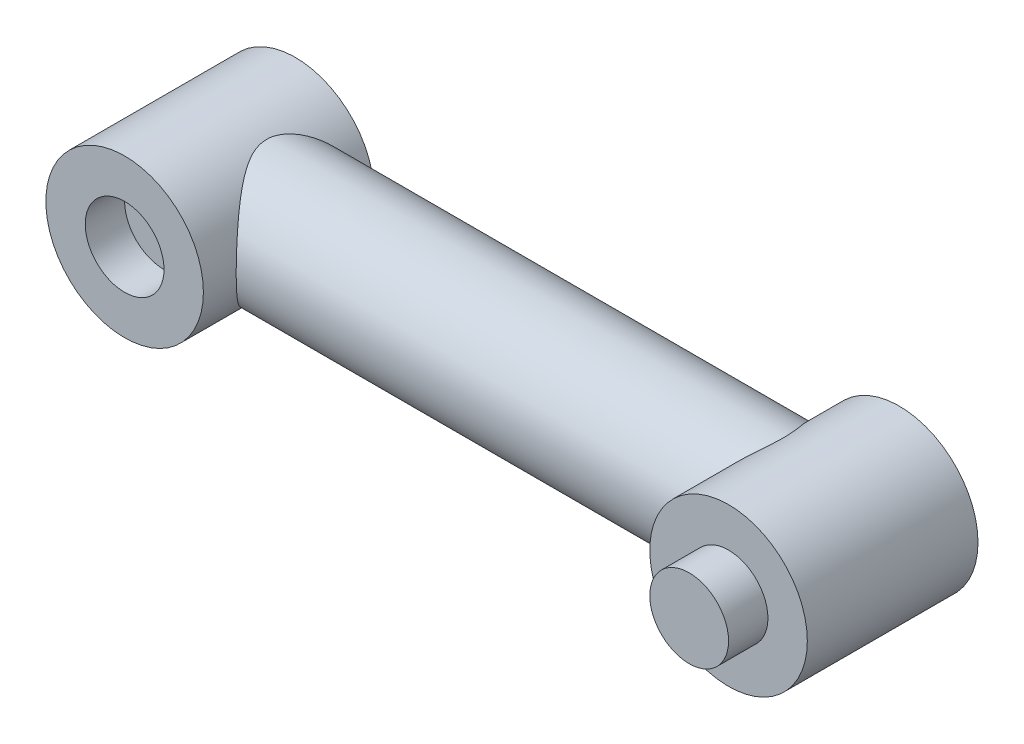
from build123d import *

# Parameters (mm, degrees)
BOSS_EXTRUDE1_START   = 5
SKETCH1_R             = 30
BOSS_EXTRUDE1_DEPTH   = 32.5
BOSS_EXTRUDE1_2_DEPTH = 32.5
SKETCH1_3_ONE_SIDE_W  = 196.833752096
SKETCH1_3_ONE_SIDE_H  = 25
CUT_EXTRUDE1_START    = 37.5
SKETCH1_4_R           = 15
CUT_EXTRUDE1_DEPTH    = 15
BOSS_EXTRUDE2_START   = 37.5
SKETCH1_5_R           = 15
BOSS_EXTRUDE2_DEPTH   = 15


with BuildPart() as part:
    # Sketch1 → Boss-Extrude1 (new body, symmetric)
    with BuildSketch(Plane.XY.offset(BOSS_EXTRUDE1_START)):
        Circle(SKETCH1_R)
    extrude(amount=BOSS_EXTRUDE1_DEPTH, both=True)



with BuildPart() as body_2:
    # Sketch1 → Boss-Extrude1 2 (new body, symmetric)
    with BuildSketch(Plane.XY.offset(BOSS_EXTRUDE1_START)):
        with Locations((230, 0)):
            Circle(SKETCH1_R)
    extrude(amount=BOSS_EXTRUDE1_2_DEPTH, both=True)


with BuildPart() as part_1:
    add(part.part)

    add(body_2.part)  # Revolve1 merges body 2
    # Sketch1_3 one side → Revolve1 (revolve)
    with BuildSketch(Plane.XY):
        with Locations((115, 12.5)):
            Rectangle(SKETCH1_3_ONE_SIDE_W, SKETCH1_3_ONE_SIDE_H)
    revolve(axis=Axis((213.416876048, 0, 0), (-1, 0, 0)))

    # Sketch1_4 → Cut-Extrude1 (cut)
    with BuildSketch(Plane.XY.offset(CUT_EXTRUDE1_START)):
        Circle(SKETCH1_4_R)
    extrude(amount=-CUT_EXTRUDE1_DEPTH, mode=Mode.SUBTRACT)

    # Sketch1_5 → Boss-Extrude2 (add)
    with BuildSketch(Plane.XY.offset(BOSS_EXTRUDE2_START)):
        with Locations((230, 0)):
            Circle(SKETCH1_5_R)
    extrude(amount=BOSS_EXTRUDE2_DEPTH)


solid = part_1.part
